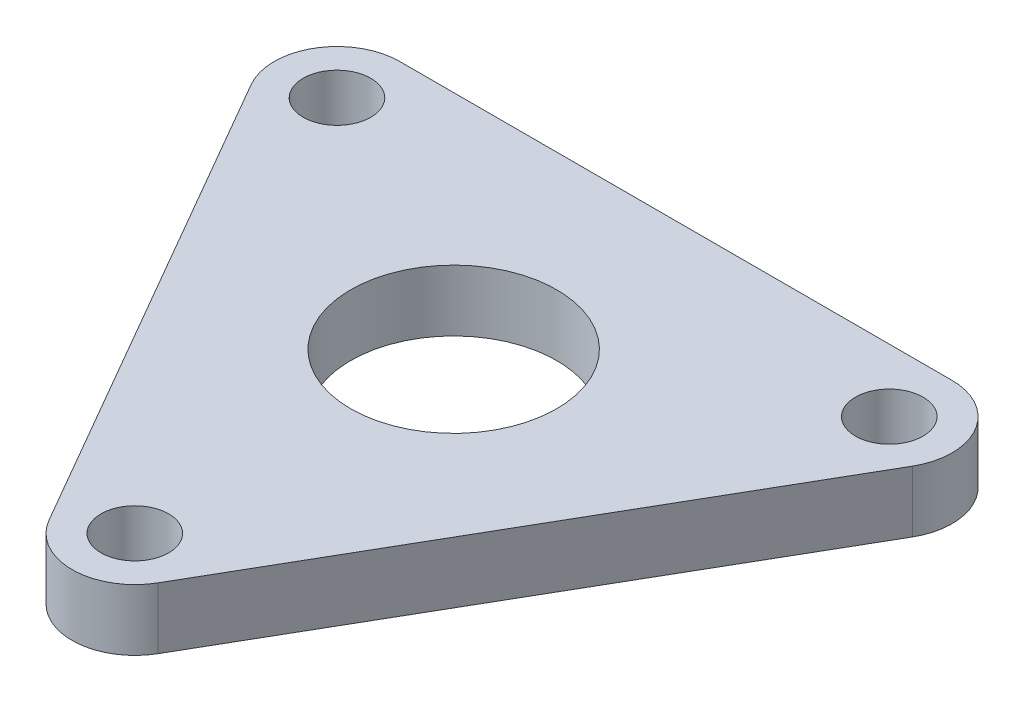
from build123d import *

# Parameters (mm, degrees)
SKETCH1_R           = 5.334
SKETCH1_R_2         = 1.75
BOSS_EXTRUDE1_DEPTH = 3.175


with BuildPart() as part:
    # Sketch1 → Boss-Extrude1 (new body)
    with BuildSketch(Plane(origin=(0, 0, 0), x_dir=(1, 0, 0), z_dir=(0, 1, 0))):
        with BuildLine():
            Line((-17.104001725, 6.625), (-2.814582562, -18.125))
            ThreePointArc((-2.814582562, -18.125), (0, -19.75), (2.814582562, -18.125))
            Line((2.814582562, -18.125), (17.104001725, 6.625))
            ThreePointArc((17.104001725, 6.625), (17.104001725, 9.875), (14.289419162, 11.5))
            Line((14.289419162, 11.5), (-14.289419162, 11.5))
            ThreePointArc((-14.289419162, 11.5), (-17.104001725, 9.875), (-17.104001725, 6.625))
        make_face()
        Circle(SKETCH1_R, mode=Mode.SUBTRACT)
        with Locations((-14.289419162, 8.25)):
            Circle(SKETCH1_R_2, mode=Mode.SUBTRACT)
        with Locations((0, -16.5)):
            Circle(SKETCH1_R_2, mode=Mode.SUBTRACT)
        with Locations((14.289419162, 8.25)):
            Circle(SKETCH1_R_2, mode=Mode.SUBTRACT)
    extrude(amount=BOSS_EXTRUDE1_DEPTH)


solid = part.part
